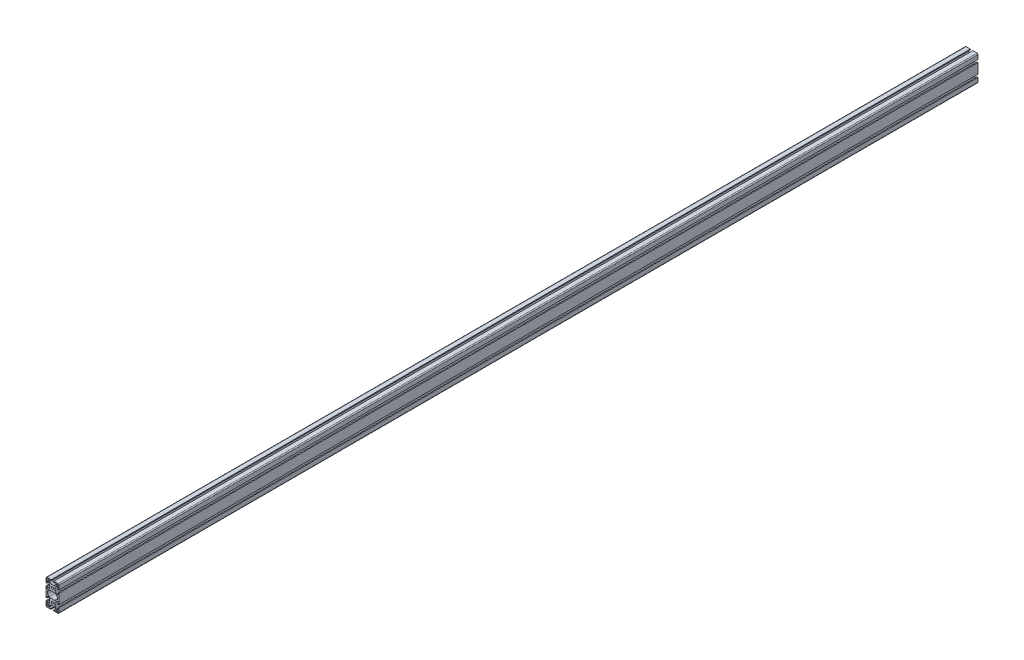
from build123d import *

# Parameters (mm, degrees)
SKETCH1_R           = 3
SKETCH1_R_2         = 3.5
BOSS_EXTRUDE1_DEPTH = 2860


with BuildPart() as part:
    # Sketch1 → Boss-Extrude1 (new body)
    with BuildSketch(Plane.XY.offset(-2897)):
        with BuildLine():
            Line((-17, -40), (-4.1, -40))
            Line((-4.1, -40), (-4.1, -37))
            Line((-4.1, -37), (-10.5, -37))
            Line((-10.5, -37), (-10.5, -33.6627417))
            ThreePointArc((-10.5, -33.6627417), (-10.378207252, -33.050448208), (-10.03137085, -32.53137085))
            Line((-10.03137085, -32.53137085), (-7.464466094, -29.964466094))
            ThreePointArc((-7.464466094, -29.964466094), (-5.84234935, -28.880602337), (-3.928932188, -28.5))
            Line((-3.928932188, -28.5), (3.928932188, -28.5))
            ThreePointArc((3.928932188, -28.5), (5.84234935, -28.880602337), (7.464466094, -29.964466094))
            Line((7.464466094, -29.964466094), (10.03137085, -32.53137085))
            ThreePointArc((10.03137085, -32.53137085), (10.378207252, -33.050448208), (10.5, -33.6627417))
            Line((10.5, -33.6627417), (10.5, -37))
            Line((10.5, -37), (4.1, -37))
            Line((4.1, -37), (4.1, -40))
            Line((4.1, -40), (17, -40))
            ThreePointArc((17, -40), (19.121320344, -39.121320344), (20, -37))
            Line((20, -37), (20, -24.1))
            Line((20, -24.1), (17, -24.1))
            Line((17, -24.1), (17, -30.5))
            Line((17, -30.5), (13.6627417, -30.5))
            ThreePointArc((13.6627417, -30.5), (13.050448208, -30.378207252), (12.53137085, -30.03137085))
            Line((12.53137085, -30.03137085), (9.964466094, -27.464466094))
            ThreePointArc((9.964466094, -27.464466094), (8.880602337, -25.84234935), (8.5, -23.928932188))
            Line((8.5, -23.928932188), (8.5, -16.071067812))
            ThreePointArc((8.5, -16.071067812), (8.880602337, -14.15765065), (9.964466094, -12.535533906))
            Line((9.964466094, -12.535533906), (12.53137085, -9.96862915))
            ThreePointArc((12.53137085, -9.96862915), (13.050448208, -9.621792748), (13.6627417, -9.5))
            Line((13.6627417, -9.5), (17, -9.5))
            Line((17, -9.5), (17, -15.9))
            Line((17, -15.9), (20, -15.9))
            Line((20, -15.9), (20, 15.9))
            Line((20, 15.9), (17, 15.9))
            Line((17, 15.9), (17, 9.5))
            Line((17, 9.5), (13.6627417, 9.5))
            ThreePointArc((13.6627417, 9.5), (13.050448208, 9.621792748), (12.53137085, 9.96862915))
            Line((12.53137085, 9.96862915), (9.964466094, 12.535533906))
            ThreePointArc((9.964466094, 12.535533906), (8.880602337, 14.15765065), (8.5, 16.071067812))
            Line((8.5, 16.071067812), (8.5, 23.928932188))
            ThreePointArc((8.5, 23.928932188), (8.880602337, 25.84234935), (9.964466094, 27.464466094))
            Line((9.964466094, 27.464466094), (12.53137085, 30.03137085))
            ThreePointArc((12.53137085, 30.03137085), (13.050448208, 30.378207252), (13.6627417, 30.5))
            Line((13.6627417, 30.5), (17, 30.5))
            Line((17, 30.5), (17, 24.1))
            Line((17, 24.1), (20, 24.1))
            Line((20, 24.1), (20, 37))
            ThreePointArc((20, 37), (19.121320344, 39.121320344), (17, 40))
            Line((17, 40), (4.1, 40))
            Line((4.1, 40), (4.1, 37))
            Line((4.1, 37), (10.5, 37))
            Line((10.5, 37), (10.5, 33.6627417))
            ThreePointArc((10.5, 33.6627417), (10.378207252, 33.050448208), (10.03137085, 32.53137085))
            Line((10.03137085, 32.53137085), (7.464466094, 29.964466094))
            ThreePointArc((7.464466094, 29.964466094), (5.84234935, 28.880602337), (3.928932188, 28.5))
            Line((3.928932188, 28.5), (-3.928932188, 28.5))
            ThreePointArc((-3.928932188, 28.5), (-5.84234935, 28.880602337), (-7.464466094, 29.964466094))
            Line((-7.464466094, 29.964466094), (-10.03137085, 32.53137085))
            ThreePointArc((-10.03137085, 32.53137085), (-10.378207252, 33.050448208), (-10.5, 33.6627417))
            Line((-10.5, 33.6627417), (-10.5, 37))
            Line((-10.5, 37), (-4.1, 37))
            Line((-4.1, 37), (-4.1, 40))
            Line((-4.1, 40), (-17, 40))
            ThreePointArc((-17, 40), (-19.121320344, 39.121320344), (-20, 37))
            Line((-20, 37), (-20, 24.1))
            Line((-20, 24.1), (-17, 24.1))
            Line((-17, 24.1), (-17, 30.5))
            Line((-17, 30.5), (-13.6627417, 30.5))
            ThreePointArc((-13.6627417, 30.5), (-13.050448208, 30.378207252), (-12.53137085, 30.03137085))
            Line((-12.53137085, 30.03137085), (-9.964466094, 27.464466094))
            ThreePointArc((-9.964466094, 27.464466094), (-8.880602337, 25.84234935), (-8.5, 23.928932188))
            Line((-8.5, 23.928932188), (-8.5, 16.071067812))
            ThreePointArc((-8.5, 16.071067812), (-8.880602337, 14.15765065), (-9.964466094, 12.535533906))
            Line((-9.964466094, 12.535533906), (-12.53137085, 9.96862915))
            ThreePointArc((-12.53137085, 9.96862915), (-13.050448208, 9.621792748), (-13.6627417, 9.5))
            Line((-13.6627417, 9.5), (-17, 9.5))
            Line((-17, 9.5), (-17, 15.9))
            Line((-17, 15.9), (-20, 15.9))
            Line((-20, 15.9), (-20, -15.9))
            Line((-20, -15.9), (-17, -15.9))
            Line((-17, -15.9), (-17, -9.5))
            Line((-17, -9.5), (-13.6627417, -9.5))
            ThreePointArc((-13.6627417, -9.5), (-13.050448208, -9.621792748), (-12.53137085, -9.96862915))
            Line((-12.53137085, -9.96862915), (-9.964466094, -12.535533906))
            ThreePointArc((-9.964466094, -12.535533906), (-8.880602337, -14.15765065), (-8.5, -16.071067812))
            Line((-8.5, -16.071067812), (-8.5, -23.928932188))
            ThreePointArc((-8.5, -23.928932188), (-8.880602337, -25.84234935), (-9.964466094, -27.464466094))
            Line((-9.964466094, -27.464466094), (-12.53137085, -30.03137085))
            ThreePointArc((-12.53137085, -30.03137085), (-13.050448208, -30.378207252), (-13.6627417, -30.5))
            Line((-13.6627417, -30.5), (-17, -30.5))
            Line((-17, -30.5), (-17, -24.1))
            Line((-17, -24.1), (-20, -24.1))
            Line((-20, -24.1), (-20, -37))
            ThreePointArc((-20, -37), (-19.121320344, -39.121320344), (-17, -40))
        make_face()
        with Locations((15, 35)):
            Circle(SKETCH1_R, mode=Mode.SUBTRACT)
        with Locations((15, -35)):
            Circle(SKETCH1_R, mode=Mode.SUBTRACT)
        with Locations((0, 20)):
            Circle(SKETCH1_R_2, mode=Mode.SUBTRACT)
        with Locations((0, -20)):
            Circle(SKETCH1_R_2, mode=Mode.SUBTRACT)
        with Locations((-15, 35)):
            Circle(SKETCH1_R, mode=Mode.SUBTRACT)
        with Locations((-15, -35)):
            Circle(SKETCH1_R, mode=Mode.SUBTRACT)
        with BuildLine():
            Line((-14.242640687, -4.242640687), (-9.949747468, -8.535533906))
            ThreePointArc((-9.949747468, -8.535533906), (-8.327630724, -9.619397663), (-6.414213562, -10))
            Line((-6.414213562, -10), (6.414213562, -10))
            ThreePointArc((6.414213562, -10), (8.327630724, -9.619397663), (9.949747468, -8.535533906))
            Line((9.949747468, -8.535533906), (14.242640687, -4.242640687))
            ThreePointArc((14.242640687, -4.242640687), (16, 0), (14.242640687, 4.242640687))
            Line((14.242640687, 4.242640687), (9.949747468, 8.535533906))
            ThreePointArc((9.949747468, 8.535533906), (8.327630724, 9.619397663), (6.414213562, 10))
            Line((6.414213562, 10), (-6.414213562, 10))
            ThreePointArc((-6.414213562, 10), (-8.327630724, 9.619397663), (-9.949747468, 8.535533906))
            Line((-9.949747468, 8.535533906), (-14.242640687, 4.242640687))
            ThreePointArc((-14.242640687, 4.242640687), (-16, 0), (-14.242640687, -4.242640687))
        make_face(mode=Mode.SUBTRACT)
    extrude(amount=BOSS_EXTRUDE1_DEPTH)


solid = part.part
